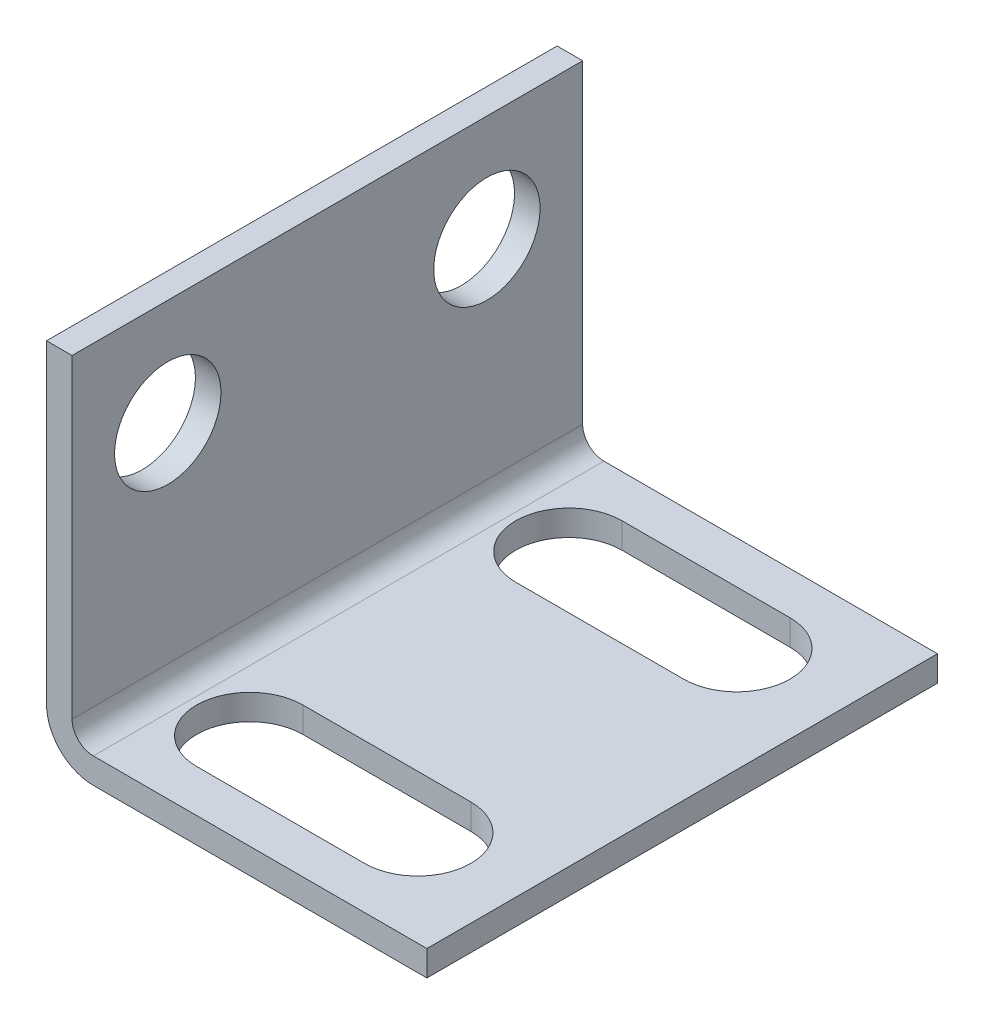
from build123d import *

# Parameters (mm, degrees)
SKETCH1_W           = 24
SKETCH1_H           = 17
SKETCH1_R           = 2.5
BOSS_EXTRUDE1_DEPTH = 1.2
SKETCH3_W           = 17.88
SKETCH3_H           = 24
BOSS_EXTRUDE3_DEPTH = 1.2
FILLET1_R           = 1
FILLET2_R           = 2.2


with BuildPart() as part:
    # Sketch1 → Boss-Extrude1 (new body)
    with BuildSketch(Plane(origin=(0, 0, 0), x_dir=(0, 0, -1), z_dir=(1, 0, 0))):
        with Locations((12, 8.5)):
            Rectangle(SKETCH1_W, SKETCH1_H)
        with Locations((4.5, 12)):
            Circle(SKETCH1_R, mode=Mode.SUBTRACT)
        with Locations((19.5, 12)):
            Circle(SKETCH1_R, mode=Mode.SUBTRACT)
    extrude(amount=BOSS_EXTRUDE1_DEPTH)

    # Sketch3 → Boss-Extrude3 (add)
    with BuildSketch(Plane(origin=(0, 0, 0), x_dir=(1, 0, 0), z_dir=(0, 1, 0))):
        with Locations((8.94, 12)):
            Rectangle(SKETCH3_W, SKETCH3_H)
        with BuildLine():
            Line((5.052758316, 22), (12.947241684, 22))
            ThreePointArc((12.947241684, 22), (15.447241684, 19.5), (12.947241684, 17))
            Line((12.947241684, 17), (5.052758316, 17))
            ThreePointArc((5.052758316, 17), (2.552758316, 19.5), (5.052758316, 22))
        make_face(mode=Mode.SUBTRACT)
        with BuildLine():
            Line((5.052758316, 7), (12.947241684, 7))
            ThreePointArc((12.947241684, 7), (15.447241684, 4.5), (12.947241684, 2))
            Line((12.947241684, 2), (5.052758316, 2))
            ThreePointArc((5.052758316, 2), (2.552758316, 4.5), (5.052758316, 7))
        make_face(mode=Mode.SUBTRACT)
    extrude(amount=BOSS_EXTRUDE3_DEPTH)

    # Fillet1
    fillet1_edges = [part.edges().sort_by_distance(p)[0] for p in [
        (1.2, 1.2, -12),
    ]]
    fillet(fillet1_edges, radius=FILLET1_R)

    # Fillet2
    fillet2_edges = [part.edges().sort_by_distance(p)[0] for p in [
        (0, 0, -12),
    ]]
    fillet(fillet2_edges, radius=FILLET2_R)


solid = part.part
